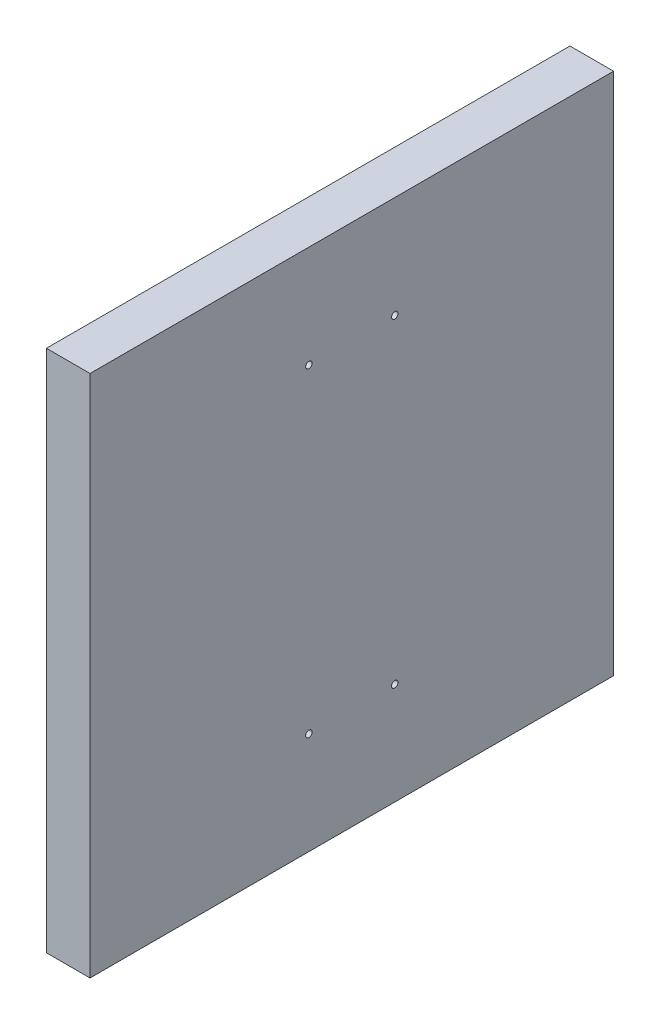
from build123d import *

# Parameters (mm, degrees)
SKETCH1_W           = 304.8
SKETCH1_H           = 304.8
BOSS_EXTRUDE1_DEPTH = 25.4
SKETCH3_R           = 1.875
CUT_EXTRUDE1_DEPTH  = 26.4


with BuildPart() as part:
    # Sketch1 → Boss-Extrude1 (new body)
    with BuildSketch(Plane(origin=(0, 0, 0), x_dir=(0, 0, -1), z_dir=(1, 0, 0))):
        Rectangle(SKETCH1_W, SKETCH1_H)
    extrude(amount=BOSS_EXTRUDE1_DEPTH)

    # Sketch3 → Cut-Extrude1 (cut, through all)
    with BuildSketch(Plane(origin=(25.4, 0, 0), x_dir=(0, 0, -1), z_dir=(1, 0, 0))):
        with Locations((-25, -93)):
            Circle(SKETCH3_R)
        with Locations((25, -93)):
            Circle(SKETCH3_R)
        with Locations((-25, 93)):
            Circle(SKETCH3_R)
        with Locations((25, 93)):
            Circle(SKETCH3_R)
    extrude(amount=-CUT_EXTRUDE1_DEPTH, mode=Mode.SUBTRACT)


solid = part.part
